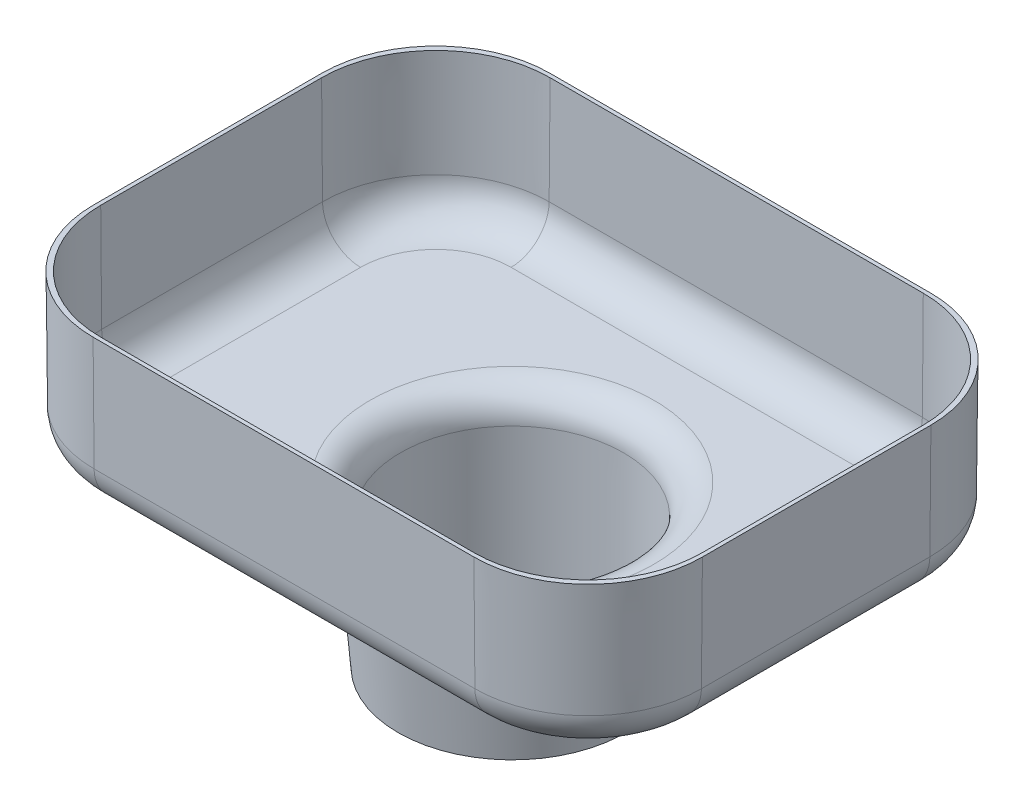
from build123d import *

# Parameters (mm, degrees)
BOSS_EXTRUDE2_DEPTH = 25.4
BOSS_EXTRUDE2_DRAFT = -0.5
CUT_EXTRUDE1_DEPTH  = 24.13
CUT_EXTRUDE1_DRAFT  = -0.5
FILLET1_R           = 6.35
FILLET2_R           = 6.35
SKETCH7_R           = 21.209
BOSS_EXTRUDE3_DEPTH = 25.4
BOSS_EXTRUDE3_TAPER = 5
SKETCH11_R          = 18.415
CUT_EXTRUDE2_DEPTH  = 26.67
CUT_EXTRUDE2_DRAFT  = 0.5
FILLET3_R           = 5.08
FILLET4_R           = 5.08


with BuildPart() as part:
    # Sketch5 → Boss-Extrude2 (with draft: the straight prism first)
    with BuildSketch(Plane(origin=(0, 0, 0), x_dir=(1, 0, 0), z_dir=(0, 1, 0))):
        with BuildLine():
            ThreePointArc((-26.568599378, 32.36603099), (-40.038983559, 26.786415172), (-45.618599378, 13.31603099))
            Line((-45.618599378, 13.31603099), (-45.618599378, -24.78396901))
            ThreePointArc((-45.618599378, -24.78396901), (-40.038983559, -38.254353191), (-26.568599378, -43.83396901))
            Line((-26.568599378, -43.83396901), (36.931400622, -43.83396901))
            ThreePointArc((36.931400622, -43.83396901), (50.401784804, -38.254353191), (55.981400622, -24.78396901))
            Line((55.981400622, -24.78396901), (55.981400622, 13.31603099))
            ThreePointArc((55.981400622, 13.31603099), (50.401784804, 26.786415172), (36.931400622, 32.36603099))
            Line((36.931400622, 32.36603099), (-26.568599378, 32.36603099))
        make_face()
    extrude(amount=-BOSS_EXTRUDE2_DEPTH)
    # Boss-Extrude2: the draft: its side faces are tilted about the plane it starts from
    boss_extrude2_sides = [part.faces().sort_by_distance(p)[0] for p in [
        (-40.038983559, -12.7, -26.786415172),
        (-45.618599378, -12.7, 5.73396901),
        (-40.038983559, -12.7, 38.254353191),
        (5.181400622, -12.7, 43.83396901),
        (50.401784804, -12.7, 38.254353191),
        (55.981400622, -12.7, 5.73396901),
        (50.401784804, -12.7, -26.786415172),
        (5.181400622, -12.7, -32.36603099),
    ]]
    draft(boss_extrude2_sides, Plane(origin=(0, 0, 0), x_dir=(1, 0, 0), z_dir=(0, 1, 0)), BOSS_EXTRUDE2_DRAFT)


with BuildPart() as cut_extrude1_tool:
    # Sketch6 → Cut-Extrude1 (with draft: the straight prism first)
    with BuildSketch(Plane(origin=(0, 0, 0), x_dir=(1, 0, 0), z_dir=(0, 1, 0))):
        with BuildLine():
            ThreePointArc((-25.933599378, 31.73103099), (-39.403983559, 26.151415172), (-44.983599378, 12.68103099))
            Line((-44.983599378, 12.68103099), (-44.983599378, -24.14896901))
            ThreePointArc((-44.983599378, -24.14896901), (-39.403983559, -37.619353191), (-25.933599378, -43.19896901))
            Line((-25.933599378, -43.19896901), (36.296400622, -43.19896901))
            ThreePointArc((36.296400622, -43.19896901), (49.766784804, -37.619353191), (55.346400622, -24.14896901))
            Line((55.346400622, -24.14896901), (55.346400622, 12.68103099))
            ThreePointArc((55.346400622, 12.68103099), (49.766784804, 26.151415172), (36.296400622, 31.73103099))
            Line((36.296400622, 31.73103099), (-25.933599378, 31.73103099))
        make_face()
    extrude(amount=-CUT_EXTRUDE1_DEPTH)
    # Cut-Extrude1: the draft: its side faces are tilted about the plane it starts from
    cut_extrude1_sides = [cut_extrude1_tool.faces().sort_by_distance(p)[0] for p in [
        (-39.403983559, -12.065, -26.151415172),
        (-44.983599378, -12.065, 5.73396901),
        (-39.403983559, -12.065, 37.619353191),
        (5.181400622, -12.065, 43.19896901),
        (49.766784804, -12.065, 37.619353191),
        (55.346400622, -12.065, 5.73396901),
        (49.766784804, -12.065, -26.151415172),
        (5.181400622, -12.065, -31.73103099),
    ]]
    draft(cut_extrude1_sides, Plane(origin=(0, 0, 0), x_dir=(1, 0, 0), z_dir=(0, 1, 0)), CUT_EXTRUDE1_DRAFT)


with BuildPart() as part_1:
    add(part.part)

    # Cut-Extrude1: cut by cut_extrude1_tool
    add(cut_extrude1_tool.part, mode=Mode.SUBTRACT)

    # Fillet1
    fillet1_edges = [part_1.edges().sort_by_distance(p)[0] for p in [
        (-39.882244543, -25.4, -26.629676156),
        (-45.396936936, -25.4, 5.73396901),
        (-39.882244543, -25.4, 38.097614176),
        (5.181400622, -25.4, 43.612306568),
        (50.245045788, -25.4, 38.097614176),
        (55.759738181, -25.4, 5.73396901),
        (50.245045788, -25.4, -26.629676156),
        (5.181400622, -25.4, -32.144368548),
    ]]
    fillet(fillet1_edges, radius=FILLET1_R)

    # Fillet2
    fillet2_edges = [part_1.edges().sort_by_distance(p)[0] for p in [
        (-39.255081494, -24.13, 37.470451126),
        (-44.773020058, -24.13, 5.73396901),
        (-39.255081494, -24.13, -26.002513107),
        (5.181400622, -24.13, -31.52045167),
        (49.617882739, -24.13, -26.002513107),
        (55.135821303, -24.13, 5.73396901),
        (49.617882739, -24.13, 37.470451126),
        (5.181400622, -24.13, 42.98838969),
    ]]
    fillet(fillet2_edges, radius=FILLET2_R)

    # Sketch7 → Boss-Extrude3 (add)
    with BuildSketch(Plane.XZ.offset(25.4)):
        with Locations((5.181400622, 5.73396901)):
            Circle(SKETCH7_R)
    extrude(amount=BOSS_EXTRUDE3_DEPTH, taper=BOSS_EXTRUDE3_TAPER)


with BuildPart() as cut_extrude2_tool:
    # Sketch11 → Cut-Extrude2 (with draft: the straight prism first)
    with BuildSketch(Plane.XZ.offset(50.8)):
        with Locations((5.181400622, 5.73396901)):
            Circle(SKETCH11_R)
    extrude(amount=-CUT_EXTRUDE2_DEPTH)
    # Cut-Extrude2: the draft: its side faces are tilted about the plane it starts from
    cut_extrude2_sides = [cut_extrude2_tool.faces().sort_by_distance(p)[0] for p in [
        (-13.233599378, -37.465, 5.73396901),
    ]]
    draft(cut_extrude2_sides, Plane.XZ.offset(50.8), CUT_EXTRUDE2_DRAFT)


with BuildPart() as part_2:
    add(part_1.part)

    # Cut-Extrude2: cut by cut_extrude2_tool
    add(cut_extrude2_tool.part, mode=Mode.SUBTRACT)

    # Fillet3
    fillet3_edges = [part_2.edges().sort_by_distance(p)[0] for p in [
        (-13.466344942, -24.13, 5.73396901),
    ]]
    fillet(fillet3_edges, radius=FILLET3_R)

    # Fillet4
    fillet4_edges = [part_2.edges().sort_by_distance(p)[0] for p in [
        (-16.027599378, -25.4, 5.73396901),
    ]]
    fillet(fillet4_edges, radius=FILLET4_R)


solid = part_2.part
